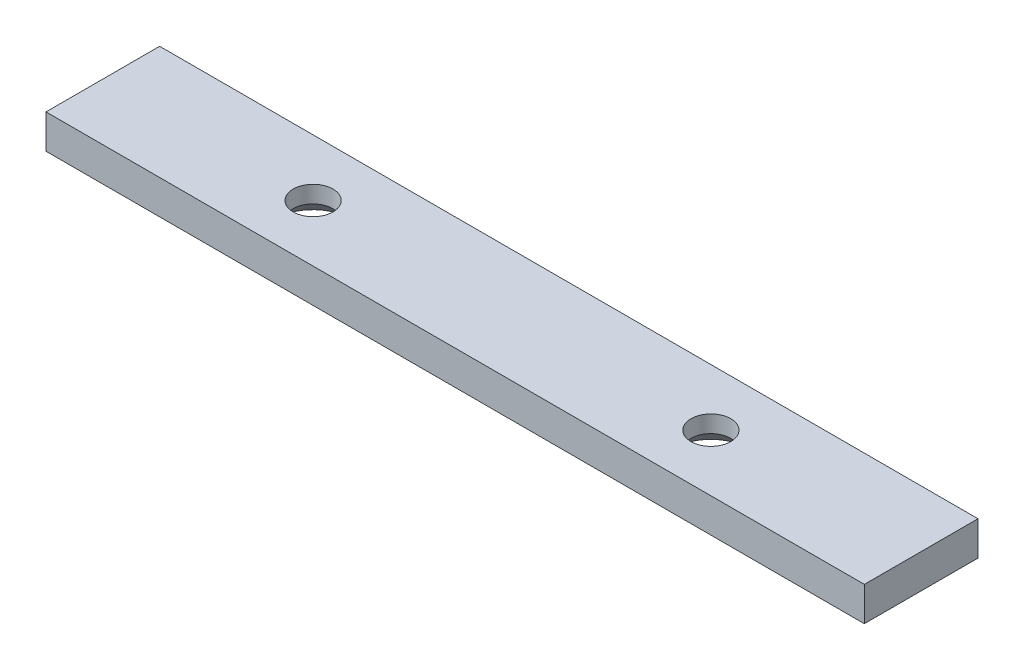
from build123d import *

# Parameters (mm, degrees)
SKETCH1_W           = 144
SKETCH1_H           = 20
SKETCH1_R           = 3.5
BOSS_EXTRUDE2_DEPTH = 6
CHAMFER3_SIZE       = 3


with BuildPart() as part:
    # Sketch1 → Boss-Extrude2 (new body)
    with BuildSketch(Plane(origin=(0, 0, 0), x_dir=(1, 0, 0), z_dir=(0, 1, 0))):
        with Locations((-35, 0)):
            Rectangle(SKETCH1_W, SKETCH1_H)
        Circle(SKETCH1_R, mode=Mode.SUBTRACT)
        with Locations((-70, 0)):
            Circle(SKETCH1_R, mode=Mode.SUBTRACT)
    extrude(amount=BOSS_EXTRUDE2_DEPTH)

    # Chamfer3
    chamfer3_edges = [part.edges().sort_by_distance(p)[0] for p in [
        (-3.5, 0, 0),
        (-73.5, 0, 0),
    ]]
    chamfer(chamfer3_edges, length=CHAMFER3_SIZE)


solid = part.part
